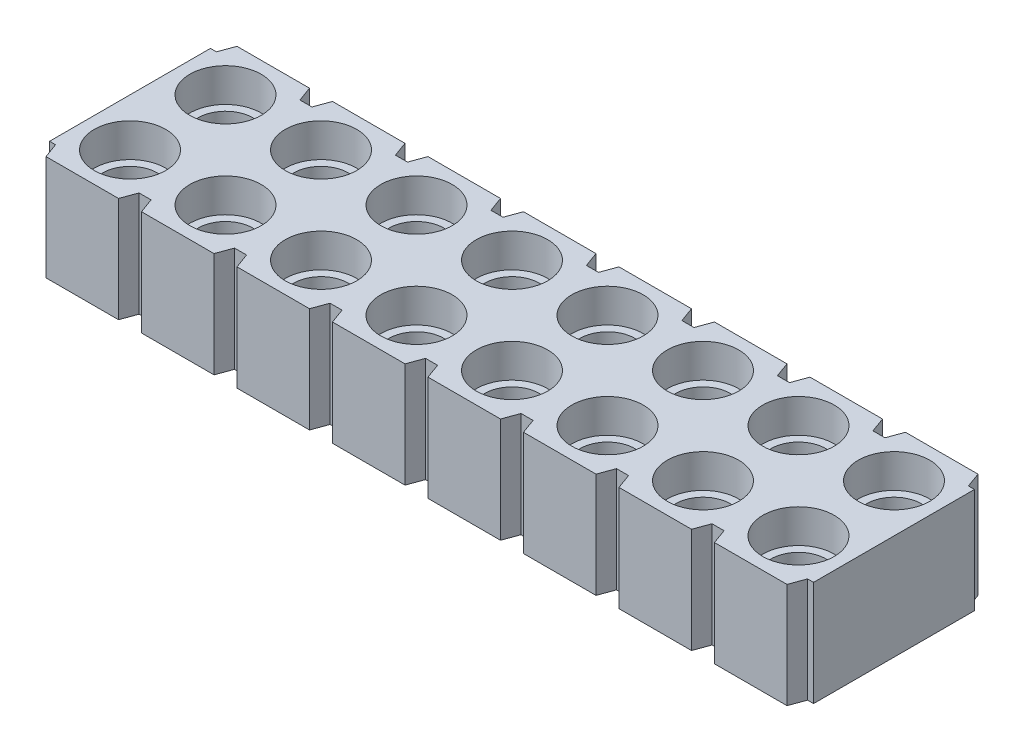
from build123d import *

# Parameters (mm, degrees)
EXTRUDE1_DEPTH          = 2.794
HOLE1_D                 = 1.459992
HOLE1_CBORE_D           = 1.89992
HOLE1_CBORE_DEPTH       = 0.89408
EXTRUDE2_DEPTH          = 2.794
HOLE_PATTERN_COUNT      = 32
HOLE_PATTERN_PITCH      = 2.54
HOLE_PATTERN_COUNT_DIR2 = 2
HOLE_PATTERN_PITCH_DIR2 = 2.54
SLOT_PATTERN_COUNT      = 31
SLOT_PATTERN_PITCH      = 2.54


with BuildPart() as part:
    # Sketch1 → Extrude1 (new body)
    with BuildSketch(Plane(origin=(0, 0, 0), x_dir=(1, 0, 0), z_dir=(0, 1, 0))):
        Polygon((20.014373708, 0.40005), (19.854353708, 0.40005), (19.708747416, 0), (0, 0), (-0.145606292, 0.40005), (-0.305626292, 0.40005), (-0.305626292, 4.67995), (-0.145606292, 4.67995), (0, 5.08), (19.708747416, 5.08), (19.854353708, 4.67995), (20.014373708, 4.67995), align=None)
    extrude(amount=-EXTRUDE1_DEPTH)

    # Hole1 (through all)
    with Locations(Plane(origin=(0.964373708, 0, -1.27), x_dir=(0, 0, 1), z_dir=(0, 1, 0))):
        with Locations((0, 0)):
            hole1 = CounterBoreHole(HOLE1_D / 2, HOLE1_CBORE_D / 2, HOLE1_CBORE_DEPTH)

    # Sketch4 → Extrude2 (cut)
    with BuildSketch(Plane(origin=(0, 0, 0), x_dir=(1, 0, 0), z_dir=(0, 1, 0))):
        Polygon((1.928772816, 0), (2.5399746, 0), (2.394368308, 0.40005), (2.074379108, 0.40005), align=None)
        Polygon((2.074379108, 4.67995), (2.394368308, 4.67995), (2.5399746, 5.08), (1.928772816, 5.08), align=None)
    extrude2 = extrude(amount=-EXTRUDE2_DEPTH, mode=Mode.SUBTRACT)

    # Hole Pattern: Hole1 32 × 2
    with Locations(*[(i * HOLE_PATTERN_PITCH, 0, -j * HOLE_PATTERN_PITCH_DIR2) for i in range(HOLE_PATTERN_COUNT) for j in range(HOLE_PATTERN_COUNT_DIR2) if (i, j) != (0, 0)]):
        add(hole1, mode=Mode.SUBTRACT)

    # Slot Pattern: Extrude2 ×31
    with Locations(*[(i * SLOT_PATTERN_PITCH, 0, 0) for i in range(1, SLOT_PATTERN_COUNT)]):
        add(extrude2, mode=Mode.SUBTRACT)


solid = part.part
